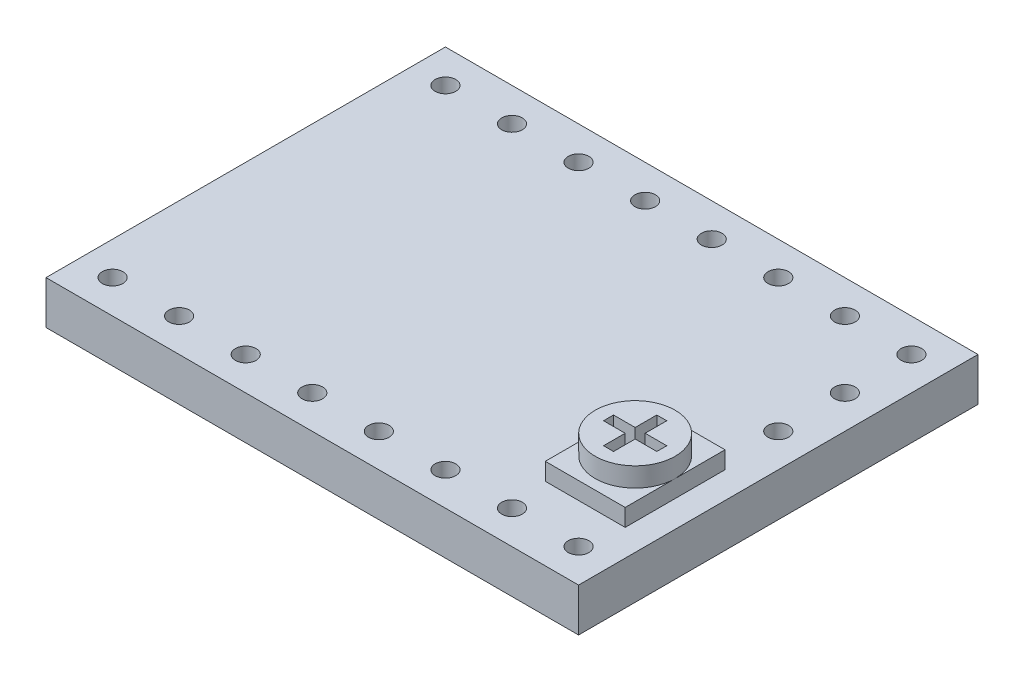
from build123d import *

# Parameters (mm, degrees)
SKETCH1_W            = 20.32
SKETCH1_H            = 15.24
BOSS_EXTRUDE1_DEPTH  = 1.651
SKETCH3_W            = 3.048
SKETCH3_H            = 3.81
BOSS_EXTRUDE3_DEPTH  = 0.6604
SKETCH4_R            = 1.524
BOSS_EXTRUDE4_DEPTH  = 0.7366
SKETCH7_R            = 0.3937
CUT_EXTRUDE2_DEPTH   = 2.651
LPATTERN2_COUNT      = 8
LPATTERN2_PITCH      = 2.54
LPATTERN2_COUNT_DIR2 = 2
LPATTERN2_PITCH_DIR2 = 12.7
CUT_EXTRUDE3_REACH   = 3.651
SKETCH8_R            = 0.3937


with BuildPart() as part:
    # Sketch1 → Boss-Extrude1 (new body)
    with BuildSketch(Plane(origin=(0, 0, 0), x_dir=(1, 0, 0), z_dir=(0, 1, 0))):
        Rectangle(SKETCH1_W, SKETCH1_H)
    extrude(amount=BOSS_EXTRUDE1_DEPTH)

    # Sketch3 → Boss-Extrude3 (add)
    with BuildSketch(Plane(origin=(0, 1.651, 0), x_dir=(1, 0, 0), z_dir=(0, 1, 0))):
        with Locations((7.62, -2.921)):
            Rectangle(SKETCH3_W, SKETCH3_H)
    extrude(amount=BOSS_EXTRUDE3_DEPTH)

    # Sketch4 → Boss-Extrude4 (add)
    with BuildSketch(Plane(origin=(0, 2.3114, 0), x_dir=(1, 0, 0), z_dir=(0, 1, 0))):
        with Locations((7.62, -2.921)):
            Circle(SKETCH4_R)
        Polygon((7.8105, -2.7305), (8.636, -2.7305), (8.636, -3.1115), (7.8105, -3.1115), (7.8105, -3.937), (7.4295, -3.937), (7.4295, -3.1115), (6.604, -3.1115), (6.604, -2.7305), (7.4295, -2.7305), (7.4295, -1.905), (7.8105, -1.905), align=None, mode=Mode.SUBTRACT)
    extrude(amount=BOSS_EXTRUDE4_DEPTH)

    # Sketch7 → Cut-Extrude2 (cut, through all)
    with BuildSketch(Plane(origin=(0, 1.651, 0), x_dir=(1, 0, 0), z_dir=(0, 1, 0))):
        with Locations((-8.89, -6.35)):
            Circle(SKETCH7_R)
    cut_extrude2 = extrude(amount=-CUT_EXTRUDE2_DEPTH, mode=Mode.SUBTRACT)

    # LPattern2: Cut-Extrude2 8 × 2
    with Locations(*[(i * LPATTERN2_PITCH, 0, -j * LPATTERN2_PITCH_DIR2) for i in range(LPATTERN2_COUNT) for j in range(LPATTERN2_COUNT_DIR2) if (i, j) != (0, 0)]):
        add(cut_extrude2, mode=Mode.SUBTRACT)

    # Sketch8 → Cut-Extrude3 (cut, up to next)
    with BuildSketch(Plane(origin=(0, 1.651, 0), x_dir=(1, 0, 0), z_dir=(0, 1, 0)), mode=Mode.PRIVATE) as cut_extrude3_sk1:
        with Locations((8.89, 3.81)):
            Circle(SKETCH8_R)
    cut_extrude3_tool1 = extrude(cut_extrude3_sk1.sketch, amount=-CUT_EXTRUDE3_REACH, mode=Mode.PRIVATE) & part.part
    add(cut_extrude3_tool1.solids().sort_by_distance((8.89, 1.651, -3.81))[0], mode=Mode.SUBTRACT)
    # Sketch8 → Cut-Extrude3 (cut, up to next)
    with BuildSketch(Plane(origin=(0, 1.651, 0), x_dir=(1, 0, 0), z_dir=(0, 1, 0)), mode=Mode.PRIVATE) as cut_extrude3_sk2:
        with Locations((8.89, 1.27)):
            Circle(SKETCH8_R)
    cut_extrude3_tool2 = extrude(cut_extrude3_sk2.sketch, amount=-CUT_EXTRUDE3_REACH, mode=Mode.PRIVATE) & part.part
    add(cut_extrude3_tool2.solids().sort_by_distance((8.89, 1.651, -1.27))[0], mode=Mode.SUBTRACT)


solid = part.part
